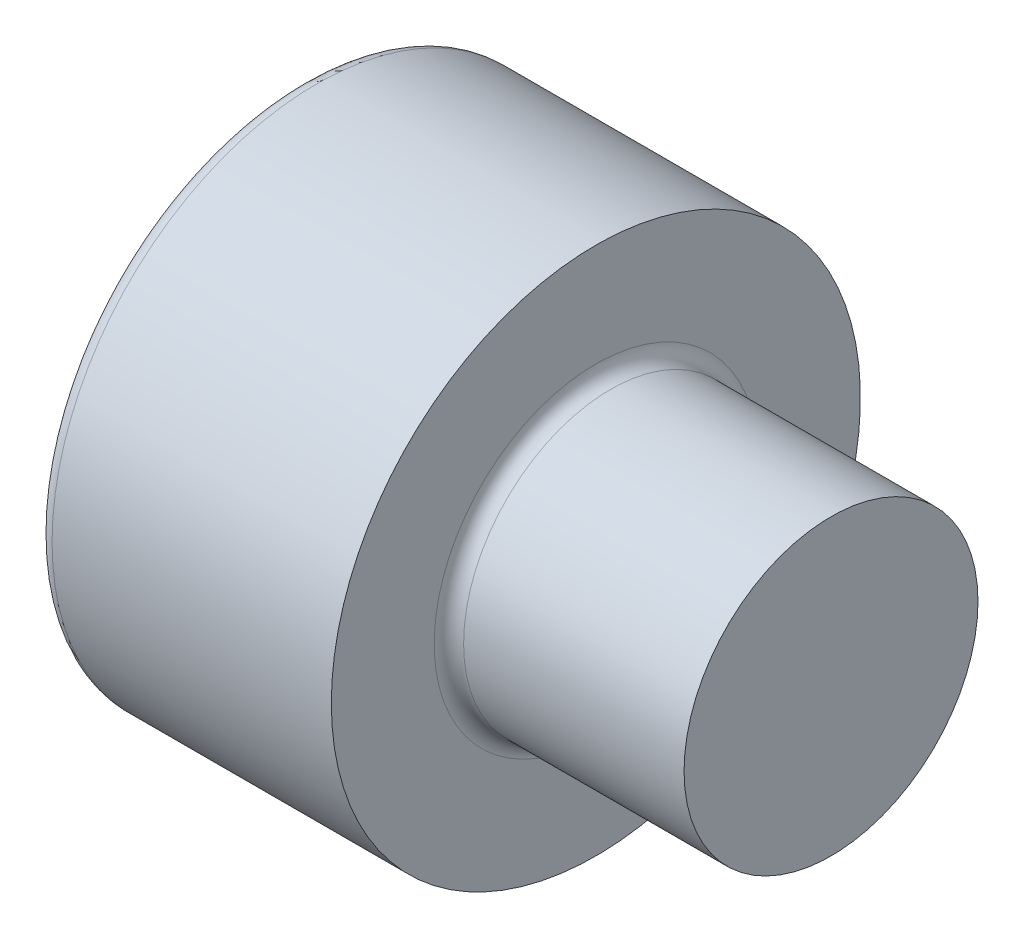
from build123d import *

# Parameters (mm, degrees)
SKETCH1_W               = 2.5
SKETCH1_H               = 2.25
SKETCH2_R               = 1.25
BOSS_EXTRUDE1_DEPTH     = 8
CUT_EXTRUDE1_DEPTH      = 1.1
CHAMFER1_SIZE           = 0.2535
FILLET1_R               = 0.125
SKETCH5_W               = 6
SKETCH5_H               = 4.609791228
CUT_EXTRUDE2_DEPTH      = 10
CUT_EXTRUDE2_DEPTH_BACK = 10


with BuildPart() as part:
    # Sketch1 → Revolve1 (revolve)
    with BuildSketch(Plane(origin=(0, 0, 0), x_dir=(-1, 0, 0), z_dir=(0, 0, -1))):
        with Locations((-1.25, 1.125)):
            Rectangle(SKETCH1_W, SKETCH1_H)
    revolve(axis=Axis((2.5, 0, 0), (-1, 0, 0)))

    # Sketch2 → Boss-Extrude1 (add)
    with BuildSketch(Plane(origin=(2.5, 0, 0), x_dir=(0, 0, -1), z_dir=(1, 0, 0))):
        Circle(SKETCH2_R)
    extrude(amount=BOSS_EXTRUDE1_DEPTH)

    # Sketch3 → Cut-Extrude1 (cut)
    with BuildSketch(Plane.ZY):
        Polygon((-1.0225, -0.59034065), (0, -1.1806813), (1.0225, -0.59034065), (1.0225, 0.59034065), (0, 1.1806813), (-1.0225, 0.59034065), align=None)
    extrude(amount=-CUT_EXTRUDE1_DEPTH, mode=Mode.SUBTRACT)

    # Sketch4 → Cut-Revolve1 (revolve, cut)
    with BuildSketch(Plane.XY):
        Polygon((1.1, 1.0225), (1.1, 0), (1.69034065, 0), align=None)
    revolve(axis=Axis((1.099975, 0, 0), (1, 0, 0)), mode=Mode.SUBTRACT)

    # Chamfer1
    chamfer1_edges = [part.edges().sort_by_distance(p)[0] for p in [
        (10.5, 0, 1.25),
    ]]
    chamfer(chamfer1_edges, length=CHAMFER1_SIZE)

    # Fillet1
    fillet1_edges = [part.edges().sort_by_distance(p)[0] for p in [
        (0, -2.25, 0),
        (2.5, 0, 1.25),
    ]]
    fillet(fillet1_edges, radius=FILLET1_R)

    # Sketch5 → Cut-Extrude2 (cut, two sides)
    with BuildSketch(Plane.XY) as cut_extrude2_sk:
        with Locations((7.5, -0.404062901)):
            Rectangle(SKETCH5_W, SKETCH5_H)
    extrude(amount=CUT_EXTRUDE2_DEPTH, mode=Mode.SUBTRACT)
    extrude(cut_extrude2_sk.sketch, amount=-CUT_EXTRUDE2_DEPTH_BACK, mode=Mode.SUBTRACT)


solid = part.part
